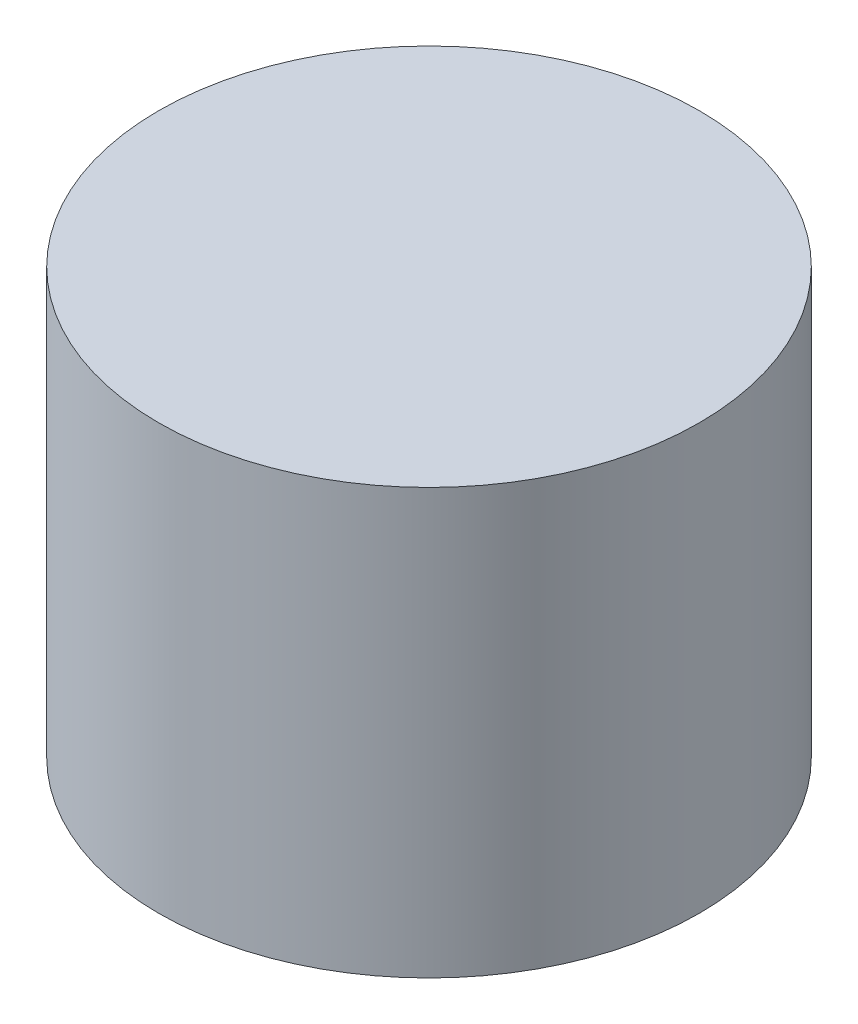
from build123d import *

# Parameters (mm, degrees)
SKETCH2_R           = 35
BOSS_EXTRUDE1_DEPTH = 55


with BuildPart() as part:
    # Sketch2 → Boss-Extrude1 (new body)
    with BuildSketch(Plane(origin=(0, 0, 0), x_dir=(1, 0, 0), z_dir=(0, 1, 0))):
        Circle(SKETCH2_R)
    extrude(amount=BOSS_EXTRUDE1_DEPTH)


solid = part.part
